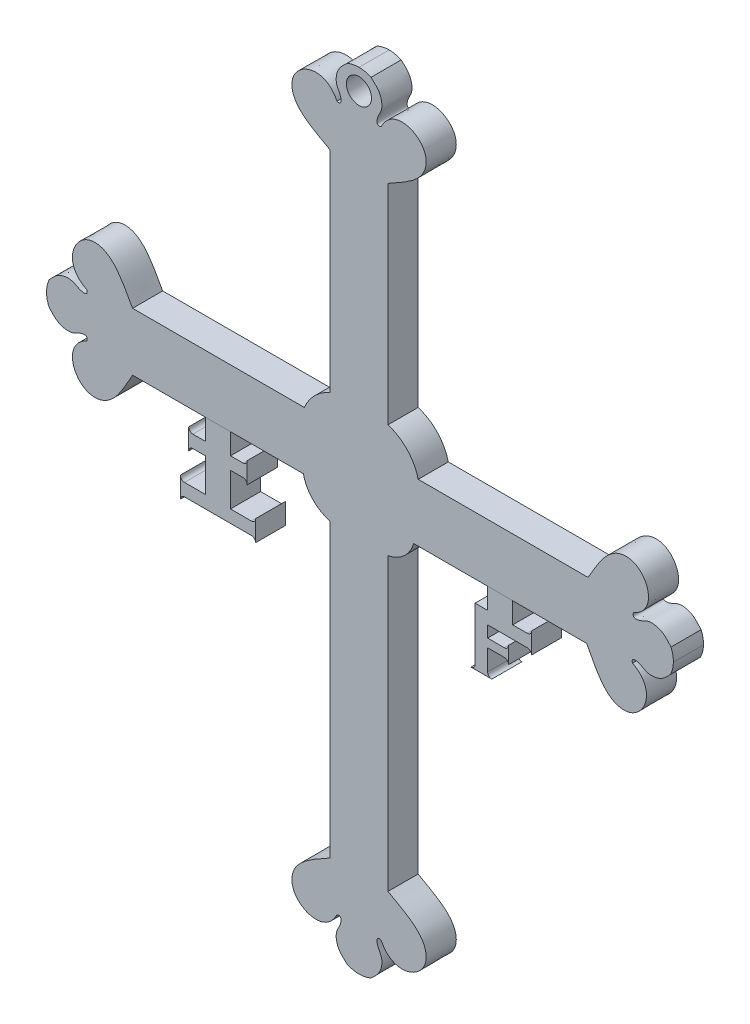
from build123d import *

# Parameters (mm, degrees)
SALIENTE_EXTRUIR1_DEPTH   = 7.2
SALIENTE_EXTRUIR2_DEPTH   = 7.2
SALIENTE_EXTRUIR2_2_DEPTH = 7.2
CROQUIS3_R                = 3
CORTAR_EXTRUIR1_DEPTH     = 7.2


with BuildPart() as part:
    # Croquis1 → Saliente-Extruir1 (new body)
    with BuildSketch(Plane.XY):
        with BuildLine():
            Line((-250.998392768, 164.74237326), (-250.998392768, 114.510626324))
            ThreePointArc((-250.998392768, 114.510626324), (-254.683172831, 112.027342318), (-257.166456837, 108.342562255))
            Line((-257.166456837, 108.342562255), (-298.225220903, 108.342562255))
            add(Edge.make_bspline(
                [(-298.225220903, 108.342562255), (-299.952370538, 111.216165413), (-302.549555631, 117.445894166), (-312.076352701, 117.598174619), (-314.972141622, 109.533238703), (-309.141169878, 106.713038746)],
                knots=[0, 0, 0, 0, 0.445418482, 0.535607619, 1, 1, 1, 1], degree=3))
            add(Edge.make_bspline(
                [(-309.141169878, 106.713038746), (-308.744080219, 105.469607871), (-310.856602918, 105.73437452), (-312.537952643, 106.98259923), (-314.7694764, 106.918500749), (-316.744226499, 105.931826273), (-317.632471198, 104.845710063), (-318.168915642, 104.303966705)],
                knots=[0, 0, 0, 0, 0.226164914, 0.394336094, 0.620843115, 0.785938977, 1, 1, 1, 1], degree=3))
            add(Edge.make_bspline(
                [(-318.168915642, 104.303966705), (-318.800785942, 102.863597113), (-318.795753938, 101.424178467)],
                knots=[0, 0, 0, 0.504567677, 0.504567677, 0.504567677], degree=2))
            add(Edge.make_bspline(
                [(-318.168915642, 98.54439023), (-318.800785942, 99.984759822), (-318.795753938, 101.424178467)],
                knots=[0, 0, 0, 0.504567677, 0.504567677, 0.504567677], degree=2))
            add(Edge.make_bspline(
                [(-309.141169878, 96.135318189), (-308.744080219, 97.378749064), (-310.856602918, 97.113982415), (-312.537952643, 95.865757705), (-314.7694764, 95.929856186), (-316.744226499, 96.916530662), (-317.632471198, 98.002646872), (-318.168915642, 98.54439023)],
                knots=[0, 0, 0, 0, 0.226164914, 0.394336094, 0.620843115, 0.785938977, 1, 1, 1, 1], degree=3))
            add(Edge.make_bspline(
                [(-298.225220903, 94.50579468), (-299.952370538, 91.632191522), (-302.549555631, 85.402462768), (-312.076352701, 85.250182316), (-314.972141622, 93.315118232), (-309.141169878, 96.135318189)],
                knots=[0, 0, 0, 0, 0.445418482, 0.535607619, 1, 1, 1, 1], degree=3))
            Line((-298.225220903, 94.50579468), (-257.398203773, 94.50579468))
            ThreePointArc((-257.398203773, 94.50579468), (-255.13581818, 90.290242388), (-250.998392768, 87.88795584))
            Line((-250.998392768, 87.88795584), (-250.998392768, 18.13498523))
            add(Edge.make_bspline(
                [(-250.998392768, 18.13498523), (-253.871995926, 16.407835595), (-260.101724679, 13.810650502), (-260.254005132, 4.283853433), (-252.189069216, 1.388064511), (-249.368869259, 7.219036255)],
                knots=[0, 0, 0, 0, 0.445418482, 0.535607619, 1, 1, 1, 1], degree=3))
            add(Edge.make_bspline(
                [(-249.368869259, 7.219036255), (-248.125438384, 7.616125915), (-248.390205033, 5.503603216), (-249.638429743, 3.82225349), (-249.574331262, 1.590729734), (-248.587656786, -0.384020366), (-247.501540576, -1.272265065), (-246.959797218, -1.808709509)],
                knots=[0, 0, 0, 0, 0.226164914, 0.394336094, 0.620843115, 0.785938977, 1, 1, 1, 1], degree=3))
            add(Edge.make_bspline(
                [(-246.959797218, -1.808709509), (-245.519427626, -2.440579809), (-244.08000898, -2.435547805)],
                knots=[0, 0, 0, 0.504567677, 0.504567677, 0.504567677], degree=2))
            add(Edge.make_bspline(
                [(-241.200220743, -1.808709509), (-242.640590335, -2.440579809), (-244.08000898, -2.435547805)],
                knots=[0, 0, 0, 0.504567677, 0.504567677, 0.504567677], degree=2))
            add(Edge.make_bspline(
                [(-238.791148702, 7.219036255), (-240.034579577, 7.616125915), (-239.769812928, 5.503603216), (-238.521588218, 3.82225349), (-238.585686699, 1.590729734), (-239.572361175, -0.384020366), (-240.658477385, -1.272265065), (-241.200220743, -1.808709509)],
                knots=[0, 0, 0, 0, 0.226164914, 0.394336094, 0.620843115, 0.785938977, 1, 1, 1, 1], degree=3))
            add(Edge.make_bspline(
                [(-237.161625193, 18.13498523), (-234.288022035, 16.407835595), (-228.058293281, 13.810650502), (-227.906012829, 4.283853433), (-235.970948745, 1.388064511), (-238.791148702, 7.219036255)],
                knots=[0, 0, 0, 0, 0.445418482, 0.535607619, 1, 1, 1, 1], degree=3))
            Line((-237.161625193, 18.13498523), (-237.161625193, 87.656208903))
            ThreePointArc((-237.161625193, 87.656208903), (-233.299041618, 89.582889089), (-231.012567177, 93.243993162))
            Line((-231.012567177, 93.243993162), (-189.655270784, 93.243993162))
            add(Edge.make_bspline(
                [(-189.655270784, 93.243993162), (-187.995372756, 90.331025688), (-185.543673616, 84.042618729), (-176.022988924, 83.668968171), (-172.940545888, 91.664424989), (-178.704398696, 94.619380164)],
                knots=[0, 0, 0, 0, 0.445418482, 0.535607619, 1, 1, 1, 1], degree=3))
            add(Edge.make_bspline(
                [(-178.704398696, 94.619380164), (-179.07248266, 95.871703897), (-176.966683978, 95.557911857), (-175.314798247, 94.270948236), (-173.082387533, 94.283166807), (-171.085239633, 95.223679827), (-170.171992547, 96.288859074), (-169.623102403, 96.817988658)],
                knots=[0, 0, 0, 0, 0.226164914, 0.394336094, 0.620843115, 0.785938977, 1, 1, 1, 1], degree=3))
            add(Edge.make_bspline(
                [(-169.623102403, 96.817988658), (-168.957927304, 98.24328397), (-168.929504579, 99.682430768)],
                knots=[0, 0, 0, 0.504567677, 0.504567677, 0.504567677], degree=2))
            add(Edge.make_bspline(
                [(-169.489244722, 102.576009437), (-168.891020565, 101.121343669), (-168.929504579, 99.682430768)],
                knots=[0, 0, 0, 0.504567677, 0.504567677, 0.504567677], degree=2))
            add(Edge.make_bspline(
                [(-178.458563061, 105.194243615), (-178.884443904, 103.960377315), (-176.766338398, 104.175975542), (-175.056432962, 105.384787036), (-172.827001659, 105.268843271), (-170.875716144, 104.236540353), (-170.012953671, 103.130073913), (-169.489244722, 102.576009437)],
                knots=[0, 0, 0, 0, 0.226164914, 0.394336094, 0.620843115, 0.785938977, 1, 1, 1, 1], degree=3))
            add(Edge.make_bspline(
                [(-189.333691998, 107.077023344), (-187.540223783, 109.909709831), (-184.798955767, 116.077395006), (-175.271192809, 116.008223088), (-172.563622342, 107.878164849), (-178.458563061, 105.194243615)],
                knots=[0, 0, 0, 0, 0.445418482, 0.535607619, 1, 1, 1, 1], degree=3))
            Line((-189.333691998, 107.077023344), (-229.938576318, 107.077023344))
            ThreePointArc((-229.938576318, 107.077023344), (-232.533499853, 111.86763996), (-237.161625193, 114.74237326))
            Line((-237.161625193, 114.74237326), (-237.161625193, 164.74237326))
            add(Edge.make_bspline(
                [(-237.161625193, 164.74237326), (-234.288022035, 166.469522895), (-228.058293281, 169.066707988), (-227.906012829, 178.593505058), (-235.970948745, 181.489293979), (-238.791148702, 175.658322236)],
                knots=[0, 0, 0, 0, 0.445418482, 0.535607619, 1, 1, 1, 1], degree=3))
            add(Edge.make_bspline(
                [(-238.791148702, 175.658322236), (-240.034579577, 175.261232576), (-239.769812928, 177.373755275), (-238.521588218, 179.055105001), (-238.585686699, 181.286628757), (-239.572361175, 183.261378857), (-240.658477385, 184.149623556), (-241.200220743, 184.686067999)],
                knots=[0, 0, 0, 0, 0.226164914, 0.394336094, 0.620843115, 0.785938977, 1, 1, 1, 1], degree=3))
            add(Edge.make_bspline(
                [(-241.200220743, 184.686067999), (-242.640590335, 185.317938299), (-244.08000898, 185.312906295)],
                knots=[0, 0, 0, 0.504567677, 0.504567677, 0.504567677], degree=2))
            add(Edge.make_bspline(
                [(-246.959797218, 184.686067999), (-245.519427626, 185.317938299), (-244.08000898, 185.312906295)],
                knots=[0, 0, 0, 0.504567677, 0.504567677, 0.504567677], degree=2))
            add(Edge.make_bspline(
                [(-249.368869259, 175.658322236), (-248.125438384, 175.261232576), (-248.390205033, 177.373755275), (-249.638429743, 179.055105001), (-249.574331262, 181.286628757), (-248.587656786, 183.261378857), (-247.501540576, 184.149623556), (-246.959797218, 184.686067999)],
                knots=[0, 0, 0, 0, 0.226164914, 0.394336094, 0.620843115, 0.785938977, 1, 1, 1, 1], degree=3))
            add(Edge.make_bspline(
                [(-250.998392768, 164.74237326), (-253.871995926, 166.469522895), (-260.101724679, 169.066707988), (-260.254005132, 178.593505058), (-252.189069216, 181.489293979), (-249.368869259, 175.658322236)],
                knots=[0, 0, 0, 0, 0.445418482, 0.535607619, 1, 1, 1, 1], degree=3))
        make_face()
    extrude(amount=SALIENTE_EXTRUIR1_DEPTH)

    # Croquis3 → Cortar-Extruir1 (cut)
    with BuildSketch(Plane.XY.offset(7.2)):
        with Locations((-244.102297491, 180.392941902)):
            Circle(CROQUIS3_R)
    extrude(amount=-CORTAR_EXTRUIR1_DEPTH, mode=Mode.SUBTRACT)


with BuildPart() as body_2:
    # Croquis2 → Saliente-Extruir2 (new body)
    with BuildSketch(Plane.XY.offset(7.2)):
        with BuildLine():
            Line((-274.811712338, 94.50579468), (-280.811712338, 94.50579468))
            Line((-280.811712338, 94.50579468), (-280.811712338, 89.50579468))
            Line((-280.811712338, 89.50579468), (-283.811712338, 89.50579468))
            ThreePointArc((-283.811712338, 89.50579468), (-284.518819119, 89.798687898), (-284.811712338, 90.50579468))
            Line((-284.811712338, 90.50579468), (-284.811712338, 85.50579468))
            ThreePointArc((-284.811712338, 85.50579468), (-284.518819119, 86.212901461), (-283.811712338, 86.50579468))
            Line((-283.811712338, 86.50579468), (-280.811712338, 86.50579468))
            Line((-280.811712338, 86.50579468), (-280.811712338, 78.50579468))
            Line((-280.811712338, 78.50579468), (-285.811712338, 78.50579468))
            ThreePointArc((-285.811712338, 78.50579468), (-286.518819119, 78.798687898), (-286.811712338, 79.50579468))
            Line((-286.811712338, 79.50579468), (-286.811712338, 74.50579468))
            ThreePointArc((-286.811712338, 74.50579468), (-286.518819119, 75.212901461), (-285.811712338, 75.50579468))
            Line((-285.811712338, 75.50579468), (-269.811712338, 75.50579468))
            ThreePointArc((-269.811712338, 75.50579468), (-269.104605557, 75.212901461), (-268.811712338, 74.50579468))
            Line((-268.811712338, 74.50579468), (-268.811712338, 79.50579468))
            ThreePointArc((-268.811712338, 79.50579468), (-269.104605557, 78.798687898), (-269.811712338, 78.50579468))
            Line((-269.811712338, 78.50579468), (-274.811712338, 78.50579468))
            Line((-274.811712338, 78.50579468), (-274.811712338, 86.50579468))
            Line((-274.811712338, 86.50579468), (-271.811712338, 86.50579468))
            ThreePointArc((-271.811712338, 86.50579468), (-271.104605557, 86.212901461), (-270.811712338, 85.50579468))
            Line((-270.811712338, 85.50579468), (-270.811712338, 90.50579468))
            ThreePointArc((-270.811712338, 90.50579468), (-271.104605557, 89.798687898), (-271.811712338, 89.50579468))
            Line((-271.811712338, 89.50579468), (-274.811712338, 89.50579468))
            Line((-274.811712338, 89.50579468), (-274.811712338, 94.50579468))
        make_face()
    extrude(amount=-SALIENTE_EXTRUIR2_DEPTH)


with BuildPart() as body_3:
    # Croquis2 → Saliente-Extruir2 2 (new body)
    with BuildSketch(Plane.XY.offset(7.2)):
        with BuildLine():
            Line((-213.33391898, 93.243993162), (-213.33391898, 88.243993162))
            Line((-213.33391898, 88.243993162), (-216.33391898, 88.243993162))
            Line((-216.33391898, 88.243993162), (-216.33391898, 75.50579468))
            ThreePointArc((-216.33391898, 75.50579468), (-216.626812199, 74.798687898), (-217.33391898, 74.50579468))
            Line((-217.33391898, 74.50579468), (-212.33391898, 74.50579468))
            ThreePointArc((-212.33391898, 74.50579468), (-213.041025762, 74.798687898), (-213.33391898, 75.50579468))
            Line((-213.33391898, 75.50579468), (-213.33391898, 80.50579468))
            Line((-213.33391898, 80.50579468), (-209.33391898, 80.50579468))
            ThreePointArc((-209.33391898, 80.50579468), (-208.626812199, 80.212901461), (-208.33391898, 79.50579468))
            Line((-208.33391898, 79.50579468), (-208.33391898, 83.50579468))
            ThreePointArc((-208.33391898, 83.50579468), (-208.626812199, 82.798687898), (-209.33391898, 82.50579468))
            Line((-209.33391898, 82.50579468), (-213.33391898, 82.50579468))
            Line((-213.33391898, 82.50579468), (-213.33391898, 83.50579468))
            Line((-213.33391898, 83.50579468), (-213.33391898, 85.24579468))
            Line((-213.33391898, 85.24579468), (-203.834819739, 85.24579468))
            ThreePointArc((-203.834819739, 85.24579468), (-203.127075739, 84.952637516), (-202.833918575, 84.244893515))
            Line((-202.833918575, 84.244893515), (-202.833918575, 89.244893515))
            ThreePointArc((-202.833918575, 89.244893515), (-203.127075739, 88.537149515), (-203.834819739, 88.243992351))
            Line((-203.834819739, 88.243992351), (-207.334819739, 88.243992351))
            Line((-207.334819739, 88.243992351), (-207.334819739, 93.243993162))
            Line((-207.334819739, 93.243993162), (-213.33391898, 93.243993162))
        make_face()
    extrude(amount=-SALIENTE_EXTRUIR2_2_DEPTH)


solid = Compound([part.part, body_2.part, body_3.part])
